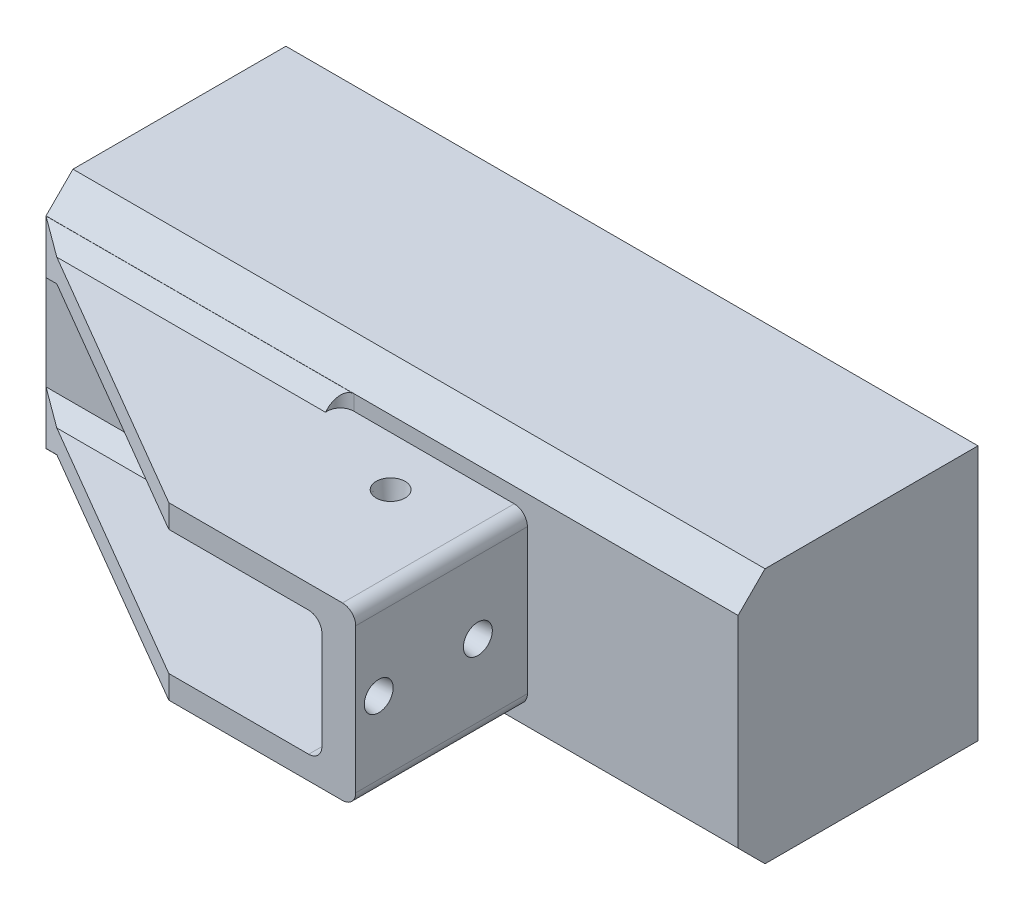
from build123d import *

# Parameters (mm, degrees)
SKETCH1_W                    = 95
SKETCH1_H                    = 49.1
BOSS_EXTRUDE1_DEPTH          = 8
SKETCH3_W                    = 10
SKETCH3_H                    = 49.1
BOSS_EXTRUDE2_DEPTH          = 38.1
SKETCH4_R                    = 1.8288
F_6_THRU_MOUNTING_HOLE_DEPTH = 11
SKETCH5_R                    = 11
CUT_EXTRUDE2_DEPTH           = 11
CIRPATTERN1_COUNT            = 4
SKETCH7_W                    = 85
SKETCH7_H                    = 38.1
BOSS_EXTRUDE5_DEPTH          = 5.5
CUT_EXTRUDE3_DEPTH           = 88.81
FILLET1_R                    = 1.5
BOSS_EXTRUDE7_DEPTH          = 4.445
SKETCH15_W                   = 6.5
SKETCH15_H                   = 23.984
BOSS_EXTRUDE8_DEPTH          = 33
CUT_EXTRUDE7_DEPTH           = 85
BOSS_EXTRUDE9_DEPTH          = 85
BOSS_EXTRUDE10_DEPTH         = 30
CHAMFER3_SIZE                = 5.18
CUT_EXTRUDE9_REACH           = 48.1
SKETCH20_W                   = 15
SKETCH20_H                   = 23.984
CHAMFER4_SIZE                = 2.9
SKETCH21_W                   = 35.914
SKETCH21_H                   = 2.9
SKETCH21_H_2                 = 2.933
CUT_EXTRUDE10_DEPTH          = 33
FILLET5_R                    = 2.54
SKETCH22_R                   = 2.7813
CUT_EXTRUDE11_DEPTH          = 3.81
CUT_EXTRUDE11_TAPER          = 8
CUT_EXTRUDE12_REACH          = 90.704
SKETCH23_R                   = 2.24583942
BOSS_EXTRUDE11_DEPTH         = 8
SKETCH25_R                   = 2.7815
CUT_EXTRUDE13_DEPTH          = 4.064
CUT_EXTRUDE13_TAPER          = 8
SKETCH26_R                   = 2.210342048
CUT_EXTRUDE14_DEPTH          = 0.381


with BuildPart() as part:
    # Sketch1 → Boss-Extrude1 (new body)
    with BuildSketch(Plane.XY):
        Rectangle(SKETCH1_W, SKETCH1_H)
    extrude(amount=BOSS_EXTRUDE1_DEPTH)

    # Sketch3 → Boss-Extrude2 (add)
    with BuildSketch(Plane(origin=(0, 0, 0), x_dir=(-1, 0, 0), z_dir=(0, 0, -1))):
        with Locations((42.5, 0)):
            Rectangle(SKETCH3_W, SKETCH3_H)
    extrude(amount=BOSS_EXTRUDE2_DEPTH)

    # Sketch4 → 6 Thru Mounting hole (cut, through all)
    with BuildSketch(Plane(origin=(-37.5, 0, 0), x_dir=(0, 0, -1), z_dir=(1, 0, 0))):
        with Locations((5.579615818, 13.470384182)):
            Circle(SKETCH4_R)
    f_6_thru_mounting_hole = extrude(amount=-F_6_THRU_MOUNTING_HOLE_DEPTH, mode=Mode.SUBTRACT)

    # Sketch5 → Cut-Extrude2 (cut, through all)
    with BuildSketch(Plane(origin=(-37.5, 0, 0), x_dir=(0, 0, -1), z_dir=(1, 0, 0))):
        with Locations((19.05, 0)):
            Circle(SKETCH5_R)
    extrude(amount=-CUT_EXTRUDE2_DEPTH, mode=Mode.SUBTRACT)

    # CirPattern1: 6 Thru Mounting hole ×4 about axis
    cirpattern1_axis = Axis((0, 0, -19.05), (1, 0, 0))
    for i in range(1, CIRPATTERN1_COUNT):
        add(f_6_thru_mounting_hole.rotate(cirpattern1_axis, i * 360 / CIRPATTERN1_COUNT), mode=Mode.SUBTRACT)

    # Sketch7 → Boss-Extrude5 (add)
    with BuildSketch(Plane(origin=(0, 24.55, 0), x_dir=(1, 0, 0), z_dir=(0, 1, 0))):
        with Locations((5, 19.05)):
            Rectangle(SKETCH7_W, SKETCH7_H)
    boss_extrude5 = extrude(amount=-BOSS_EXTRUDE5_DEPTH)

    # Mirror1: Boss-Extrude5 across plane
    add(boss_extrude5.mirror(Plane.ZX))

    # Sketch8 → Cut-Extrude3 (cut)
    with BuildSketch(Plane(origin=(47.5, 0, 0), x_dir=(0, 0, -1), z_dir=(1, 0, 0))):
        with BuildLine():
            Line((9.673473228, 13.831299494), (7.807002179, 15.697770542))
            ThreePointArc((7.807002179, 15.697770542), (5.579615818, 16.620384182), (3.352229458, 15.697770542))
            ThreePointArc((3.352229458, 15.697770542), (3.31709371, 15.661572196), (3.282039166, 15.625295207))
            ThreePointArc((3.282039166, 15.625295207), (2.430019787, 13.419937796), (3.352229458, 11.242997821))
            Line((3.352229458, 11.242997821), (5.218700506, 9.376526772))
            ThreePointArc((5.218700506, 9.376526772), (2.34, 0), (5.218700506, -9.376526772))
            Line((5.218700506, -9.376526772), (3.352229458, -11.242997821))
            ThreePointArc((3.352229458, -11.242997821), (2.430019787, -13.419937796), (3.282039166, -15.625295207))
            ThreePointArc((3.282039166, -15.625295207), (3.31709371, -15.661572196), (3.352229458, -15.697770542))
            ThreePointArc((3.352229458, -15.697770542), (5.579615818, -16.620384182), (7.807002179, -15.697770542))
            Line((7.807002179, -15.697770542), (9.673473228, -13.831299494))
            ThreePointArc((9.673473228, -13.831299494), (19.05, -16.71), (28.426526772, -13.831299494))
            Line((28.426526772, -13.831299494), (30.292997821, -15.697770542))
            ThreePointArc((30.292997821, -15.697770542), (34.747770542, -15.697770542), (34.747770542, -11.242997821))
            Line((34.747770542, -11.242997821), (32.881299494, -9.376526772))
            ThreePointArc((32.881299494, -9.376526772), (35.76, 0), (32.881299494, 9.376526772))
            Line((32.881299494, 9.376526772), (34.747770542, 11.242997821))
            ThreePointArc((34.747770542, 11.242997821), (34.747770542, 15.697770542), (30.292997821, 15.697770542))
            Line((30.292997821, 15.697770542), (28.426526772, 13.831299494))
            ThreePointArc((28.426526772, 13.831299494), (19.05, 16.71), (9.673473228, 13.831299494))
        make_face()
        with BuildLine():
            ThreePointArc((3.352229458, 11.242997821), (2.430019787, 13.419937796), (3.282039166, 15.625295207))
            ThreePointArc((3.282039166, 15.625295207), (1.50861691, 13.547063418), (0, 11.269312578))
            Line((0, 11.269312578), (0, -11.269312578))
            ThreePointArc((0, -11.269312578), (1.50861691, -13.547063418), (3.282039166, -15.625295207))
            ThreePointArc((3.282039166, -15.625295207), (2.430019787, -13.419937796), (3.352229458, -11.242997821))
            Line((3.352229458, -11.242997821), (5.218700506, -9.376526772))
            ThreePointArc((5.218700506, -9.376526772), (2.34, 0), (5.218700506, 9.376526772))
            Line((5.218700506, 9.376526772), (3.352229458, 11.242997821))
        make_face()
        with BuildLine():
            Line((0, -11.269312578), (0, 11.269312578))
            ThreePointArc((0, 11.269312578), (-3.023693761, 0), (0, -11.269312578))
        make_face()
    extrude(amount=-CUT_EXTRUDE3_DEPTH, mode=Mode.SUBTRACT)

    # Fillet1
    fillet1_edges = [part.edges().sort_by_distance(p)[0] for p in [
        (-39.405, 13.831299494, -9.673473228),
        (-39.405, 13.831299494, -28.426526772),
        (-39.405, 9.376526772, -32.881299494),
        (-39.405, -9.376526772, -32.881299494),
        (-39.405, -13.831299494, -28.426526772),
        (-39.405, -13.831299494, -9.673473228),
    ]]
    fillet(fillet1_edges, radius=FILLET1_R)

    # Sketch14 → Boss-Extrude7 (add)
    with BuildSketch(Plane(origin=(0, 16.437, 0), x_dir=(1, 0, 0), z_dir=(0, 1, 0))):
        Polygon((45.014, -8), (45.014, -41), (9.1, -41), (-47.5, -8), (9.1, -8), align=None)
    boss_extrude7 = extrude(amount=-BOSS_EXTRUDE7_DEPTH)

    # Mirror2: Boss-Extrude7 across plane
    add(boss_extrude7.mirror(Plane.ZX))

    # Sketch15 → Boss-Extrude8 (add)
    with BuildSketch(Plane.XY.offset(8)):
        with Locations((41.764, 0)):
            Rectangle(SKETCH15_W, SKETCH15_H)
    extrude(amount=BOSS_EXTRUDE8_DEPTH)

    # Sketch16 → Cut-Extrude7 (cut)
    with BuildSketch(Plane(origin=(-37.5, 0, 0), x_dir=(0, 0, -1), z_dir=(1, 0, 0))):
        with BuildLine():
            Line((0, 11.399013115), (0, -11.399013115))
            ThreePointArc((0, -11.399013115), (-3.15, 0), (0, 11.399013115))
        make_face()
    extrude(amount=CUT_EXTRUDE7_DEPTH, mode=Mode.SUBTRACT)

    # Sketch17 → Boss-Extrude9 (add)
    with BuildSketch(Plane(origin=(-37.5, 0, 0), x_dir=(0, 0, -1), z_dir=(1, 0, 0))):
        with BuildLine():
            Line((0, 11.399013115), (0, 19.05))
            Line((0, 19.05), (7.650986885, 19.05))
            ThreePointArc((7.650986885, 19.05), (3.352229458, 15.697770542), (0, 11.399013115))
        make_face()
        with BuildLine():
            Line((0, -19.05), (7.650986885, -19.05))
            ThreePointArc((7.650986885, -19.05), (3.352229458, -15.697770542), (0, -11.399013115))
            Line((0, -11.399013115), (0, -19.05))
        make_face()
    extrude(amount=BOSS_EXTRUDE9_DEPTH)

    # Sketch19 → Boss-Extrude10 (add)
    with BuildSketch(Plane(origin=(47.5, 0, 0), x_dir=(0, 0, -1), z_dir=(1, 0, 0))):
        with BuildLine():
            Line((38.1, -19.05), (7.650986885, -19.05))
            ThreePointArc((7.650986885, -19.05), (-3.15, 0), (7.650986885, 19.05))
            Line((7.650986885, 19.05), (38.1, 19.05))
            Line((38.1, 19.05), (38.1, 24.55))
            Line((38.1, 24.55), (-8, 24.55))
            Line((-8, 24.55), (-8, -24.55))
            Line((-8, -24.55), (38.1, -24.55))
            Line((38.1, -24.55), (38.1, -19.05))
        make_face()
    extrude(amount=BOSS_EXTRUDE10_DEPTH)

    # Chamfer3
    chamfer3_edges = [part.edges().sort_by_distance(p)[0] for p in [
        (15, -24.55, 8),
        (15, 24.55, 8),
    ]]
    chamfer(chamfer3_edges, length=CHAMFER3_SIZE)

    # Sketch20 → Cut-Extrude9 (cut, up to next)
    with BuildSketch(Plane.XY.offset(8), mode=Mode.PRIVATE) as cut_extrude9_sk1:
        with Locations((31.014, 0)):
            Rectangle(SKETCH20_W, SKETCH20_H)
    cut_extrude9_tool1 = extrude(cut_extrude9_sk1.sketch, amount=-CUT_EXTRUDE9_REACH, mode=Mode.PRIVATE) & part.part
    add(cut_extrude9_tool1.solids().sort_by_distance((31.014, 0, 8))[0], mode=Mode.SUBTRACT)

    # Chamfer4
    chamfer4_edges = [part.edges().sort_by_distance(p)[0] for p in [
        (-1.243, 16.437, 8),
        (-1.243, -16.437, 8),
        (-11.993, -11.992, 8),
        (-11.993, 11.992, 8),
    ]]
    chamfer(chamfer4_edges, length=CHAMFER4_SIZE)

    # Sketch21 → Cut-Extrude10 (cut)
    with BuildSketch(Plane.XY.offset(41)):
        with Locations((27.057, 17.887)):
            Rectangle(SKETCH21_W, SKETCH21_H)
        with Locations((27.057, -17.9035)):
            Rectangle(SKETCH21_W, SKETCH21_H_2)
    extrude(amount=-CUT_EXTRUDE10_DEPTH, mode=Mode.SUBTRACT)

    # Fillet5
    fillet5_edges = [part.edges().sort_by_distance(p)[0] for p in [
        (45.014, 16.437, 24.5),
        (45.014, -16.437, 24.5),
        (38.514, 11.992, 20.31619821),
        (38.514, -11.992, 20.31619821),
        (23.514, -11.992, 5.26619821),
        (23.514, 11.992, 5.26619821),
        (9.1, 17.887, 8),
        (9.1, -17.887, 8),
    ]]
    fillet(fillet5_edges, radius=FILLET5_R)

    # Sketch22 → Cut-Extrude11 (cut)
    with BuildSketch(Plane(origin=(45.014, 0, 0), x_dir=(0, 0, -1), z_dir=(1, 0, 0))):
        with Locations((-17.525, 0)):
            Circle(SKETCH22_R)
        with Locations((-36.575, 0)):
            Circle(SKETCH22_R)
    extrude(amount=-CUT_EXTRUDE11_DEPTH, taper=CUT_EXTRUDE11_TAPER, mode=Mode.SUBTRACT)

    # Sketch23 → Cut-Extrude12 (cut, up to next)
    with BuildSketch(Plane(origin=(41.204, 0, 0), x_dir=(0, 0, -1), z_dir=(1, 0, 0)), mode=Mode.PRIVATE) as cut_extrude12_sk1:
        with Locations((-17.525, 0)):
            Circle(SKETCH23_R)
    cut_extrude12_tool1 = extrude(cut_extrude12_sk1.sketch, amount=-CUT_EXTRUDE12_REACH, mode=Mode.PRIVATE) & part.part
    add(cut_extrude12_tool1.solids().sort_by_distance((41.204, 0, 17.525))[0], mode=Mode.SUBTRACT)
    # Sketch23 → Cut-Extrude12 (cut, up to next)
    with BuildSketch(Plane(origin=(41.204, 0, 0), x_dir=(0, 0, -1), z_dir=(1, 0, 0)), mode=Mode.PRIVATE) as cut_extrude12_sk2:
        with Locations((-36.575, 0)):
            Circle(SKETCH23_R)
    cut_extrude12_tool2 = extrude(cut_extrude12_sk2.sketch, amount=-CUT_EXTRUDE12_REACH, mode=Mode.PRIVATE) & part.part
    add(cut_extrude12_tool2.solids().sort_by_distance((41.204, 0, 36.575))[0], mode=Mode.SUBTRACT)

    # Sketch24 → Boss-Extrude11 (add)
    with BuildSketch(Plane(origin=(77.5, 0, 0), x_dir=(0, 0, -1), z_dir=(1, 0, 0))):
        Polygon((38.1, 19.05), (38.1, -19.05), (38.1, -24.55), (-2.82, -24.55), (-8, -19.37), (-8, 19.37), (-2.82, 24.55), (38.1, 24.55), align=None)
    extrude(amount=BOSS_EXTRUDE11_DEPTH)

    # Sketch25 → Cut-Extrude13 (cut)
    with BuildSketch(Plane.XZ.offset(16.437)):
        with Locations((28.25, 17.525)):
            Circle(SKETCH25_R)
    cut_extrude13 = extrude(amount=-CUT_EXTRUDE13_DEPTH, taper=CUT_EXTRUDE13_TAPER, mode=Mode.SUBTRACT)

    # Sketch26 → Cut-Extrude14 (cut)
    with BuildSketch(Plane.XZ.offset(12.373)):
        with Locations((28.25, 17.525)):
            Circle(SKETCH26_R)
    cut_extrude14 = extrude(amount=-CUT_EXTRUDE14_DEPTH, mode=Mode.SUBTRACT)

    # Mirror3: Cut-Extrude13, Cut-Extrude14 across plane
    add(cut_extrude13.mirror(Plane.ZX), mode=Mode.SUBTRACT)
    add(cut_extrude14.mirror(Plane.ZX), mode=Mode.SUBTRACT)


solid = part.part
